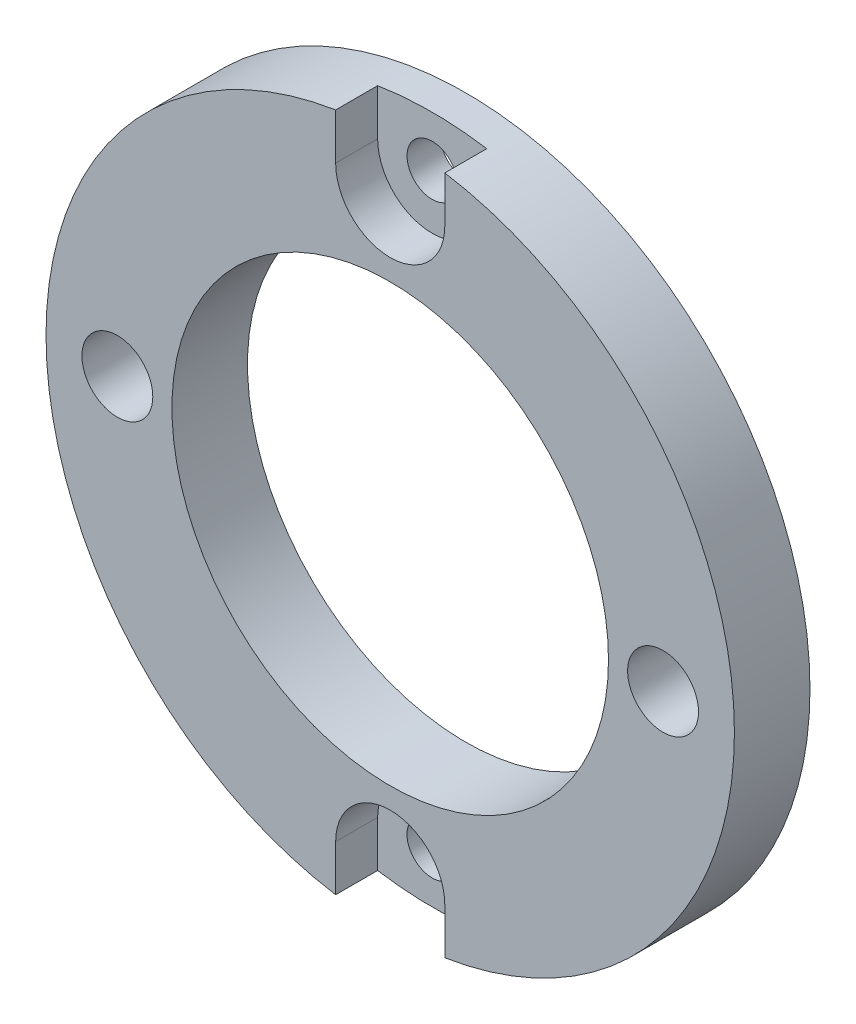
from build123d import *

# Parameters (mm, degrees)
ESQUISSE1_R             = 20.5
ESQUISSE1_R_2           = 13
BOSS_EXTRU_1_DEPTH      = 4.5
ENL_V_MAT_EXTRU_1_REACH = 6.5
ESQUISSE2_R             = 1.5
ESQUISSE2_R_2           = 2.11
ENL_V_MAT_EXTRU_2_DEPTH = 2.5


with BuildPart() as part:
    # Esquisse1 → Boss.-Extru.1 (new body)
    with BuildSketch(Plane.XY):
        Circle(ESQUISSE1_R)
        Circle(ESQUISSE1_R_2, mode=Mode.SUBTRACT)
    extrude(amount=BOSS_EXTRU_1_DEPTH)

    # Esquisse2 → Enlèv. mat.-Extru.1 (cut, up to next)
    with BuildSketch(Plane.XY.offset(4.5), mode=Mode.PRIVATE) as enl_v_mat_extru_1_sk1:
        with Locations((0, 17.5)):
            Circle(ESQUISSE2_R)
    enl_v_mat_extru_1_tool1 = extrude(enl_v_mat_extru_1_sk1.sketch, amount=-ENL_V_MAT_EXTRU_1_REACH, mode=Mode.PRIVATE) & part.part
    add(enl_v_mat_extru_1_tool1.solids().sort_by_distance((0, 17.5, 4.5))[0], mode=Mode.SUBTRACT)
    # Esquisse2 → Enlèv. mat.-Extru.1 (cut, up to next)
    with BuildSketch(Plane.XY.offset(4.5), mode=Mode.PRIVATE) as enl_v_mat_extru_1_sk2:
        with Locations((16.25, 0)):
            Circle(ESQUISSE2_R_2)
    enl_v_mat_extru_1_tool2 = extrude(enl_v_mat_extru_1_sk2.sketch, amount=-ENL_V_MAT_EXTRU_1_REACH, mode=Mode.PRIVATE) & part.part
    add(enl_v_mat_extru_1_tool2.solids().sort_by_distance((16.25, 0, 4.5))[0], mode=Mode.SUBTRACT)
    # Esquisse2 → Enlèv. mat.-Extru.1 (cut, up to next)
    with BuildSketch(Plane.XY.offset(4.5), mode=Mode.PRIVATE) as enl_v_mat_extru_1_sk3:
        with Locations((0, -17.5)):
            Circle(ESQUISSE2_R)
    enl_v_mat_extru_1_tool3 = extrude(enl_v_mat_extru_1_sk3.sketch, amount=-ENL_V_MAT_EXTRU_1_REACH, mode=Mode.PRIVATE) & part.part
    add(enl_v_mat_extru_1_tool3.solids().sort_by_distance((0, -17.5, 4.5))[0], mode=Mode.SUBTRACT)
    # Esquisse2 → Enlèv. mat.-Extru.1 (cut, up to next)
    with BuildSketch(Plane.XY.offset(4.5), mode=Mode.PRIVATE) as enl_v_mat_extru_1_sk4:
        with Locations((-16.25, 0)):
            Circle(ESQUISSE2_R_2)
    enl_v_mat_extru_1_tool4 = extrude(enl_v_mat_extru_1_sk4.sketch, amount=-ENL_V_MAT_EXTRU_1_REACH, mode=Mode.PRIVATE) & part.part
    add(enl_v_mat_extru_1_tool4.solids().sort_by_distance((-16.25, 0, 4.5))[0], mode=Mode.SUBTRACT)

    # Esquisse3 → Enlèv. mat.-Extru.2 (cut)
    with BuildSketch(Plane.XY.offset(4.5)):
        with BuildLine():
            Line((-3.25, 17.5), (-3.25, 27.5))
            Line((-3.25, 27.5), (3.25, 27.5))
            Line((3.25, 27.5), (3.25, 17.5))
            ThreePointArc((3.25, 17.5), (0, 14.25), (-3.25, 17.5))
        make_face()
        with BuildLine():
            Line((-3.25, -27.5), (3.25, -27.5))
            Line((3.25, -27.5), (3.25, -17.5))
            ThreePointArc((3.25, -17.5), (0, -14.25), (-3.25, -17.5))
            Line((-3.25, -17.5), (-3.25, -27.5))
        make_face()
    extrude(amount=-ENL_V_MAT_EXTRU_2_DEPTH, mode=Mode.SUBTRACT)


solid = part.part
